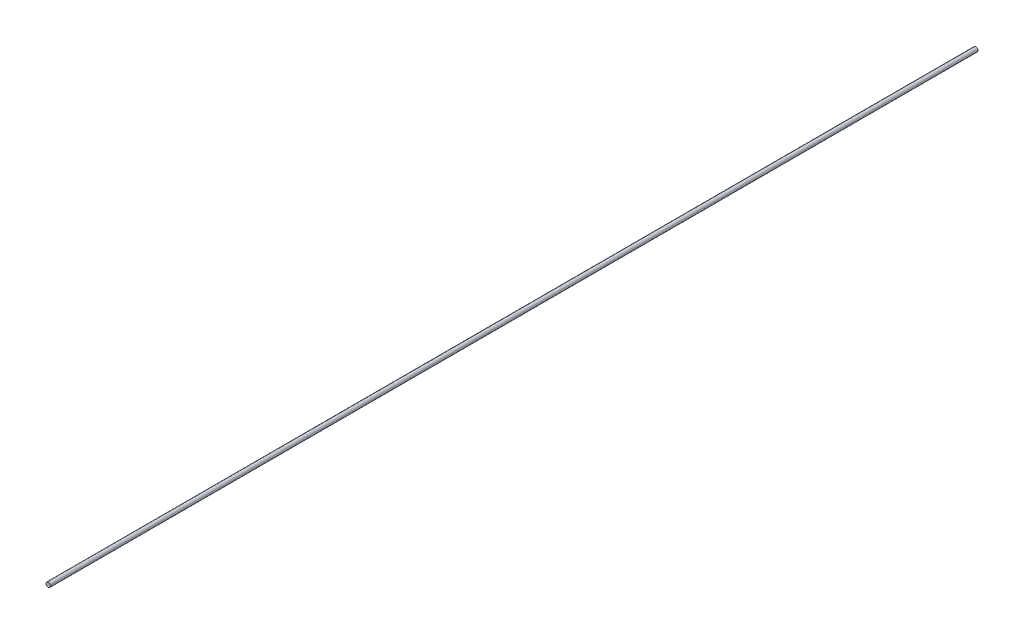
from build123d import *

# Parameters (mm, degrees)
SKETCH1_R           = 3.8
BOSS_EXTRUDE1_DEPTH = 1586


with BuildPart() as part:
    # Sketch1 → Boss-Extrude1 (new body)
    with BuildSketch(Plane.XY):
        Circle(SKETCH1_R)
    extrude(amount=BOSS_EXTRUDE1_DEPTH)


solid = part.part
